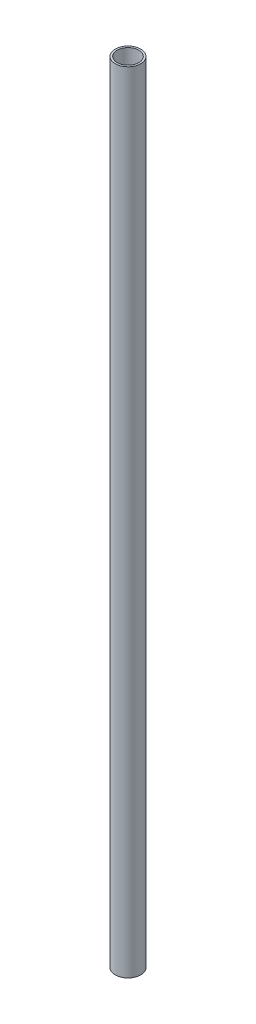
from build123d import *

# Parameters (mm, degrees)
SKETCH1_R           = 20
BOSS_EXTRUDE1_DEPTH = 1240
CUT_EXTRUDE1_REACH  = 1242
SKETCH2_R           = 17


with BuildPart() as part:
    # Sketch1 → Boss-Extrude1 (new body)
    with BuildSketch(Plane(origin=(0, 0, 0), x_dir=(1, 0, 0), z_dir=(0, 1, 0))):
        Circle(SKETCH1_R)
    extrude(amount=BOSS_EXTRUDE1_DEPTH)

    # Sketch2 → Cut-Extrude1 (cut, up to next)
    with BuildSketch(Plane(origin=(0, 1240, 0), x_dir=(1, 0, 0), z_dir=(0, 1, 0)), mode=Mode.PRIVATE) as cut_extrude1_sk1:
        Circle(SKETCH2_R)
    cut_extrude1_tool1 = extrude(cut_extrude1_sk1.sketch, amount=-CUT_EXTRUDE1_REACH, mode=Mode.PRIVATE) & part.part
    add(cut_extrude1_tool1.solids().sort_by_distance((0, 1240, 0))[0], mode=Mode.SUBTRACT)


solid = part.part
